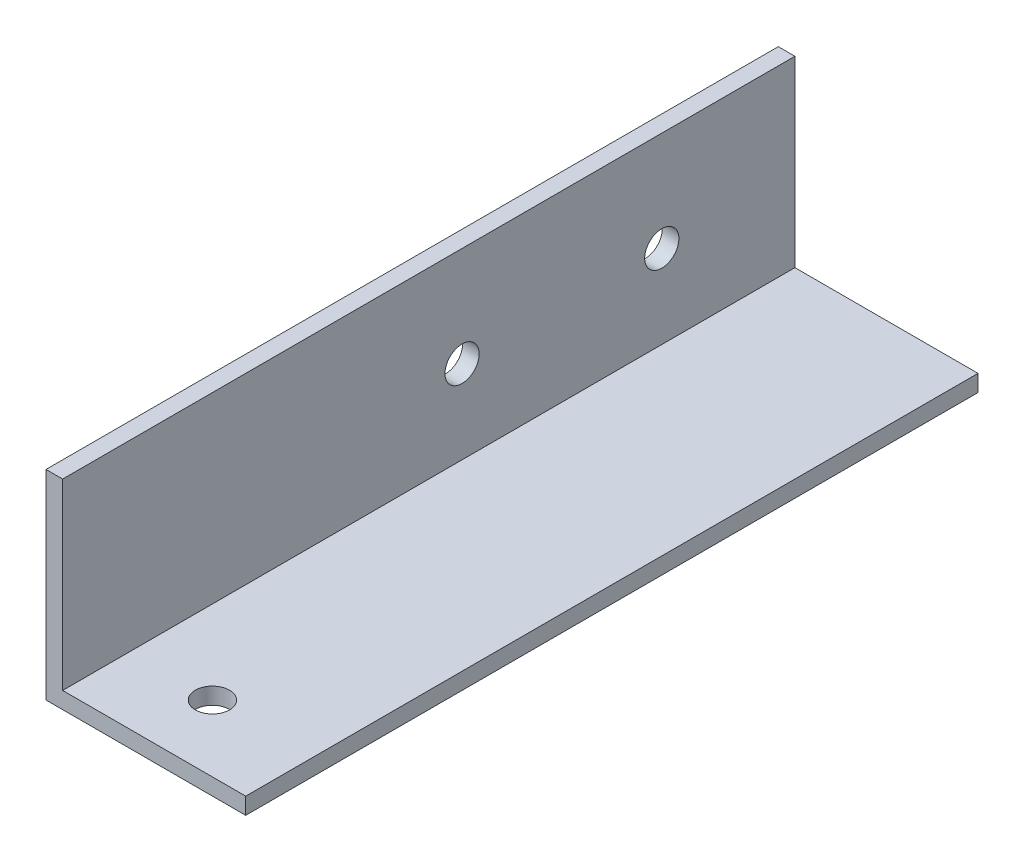
from build123d import *

# Parameters (mm, degrees)
BOSS_EXTRUDE1_DEPTH   = 69.85
F_4_CLEARANCE_HOLE1_D = 3.2639
F_4_CLEARANCE_HOLE2_D = 3.2639


with BuildPart() as part:
    # Sketch1 → Boss-Extrude1 (new body)
    with BuildSketch(Plane.XY):
        Polygon((0, 0), (0, 19.05), (1.5875, 19.05), (1.5875, 1.5875), (19.05, 1.5875), (19.05, 0), align=None)
    extrude(amount=BOSS_EXTRUDE1_DEPTH)

    # #4 Clearance Hole1 (through all)
    with Locations(Plane(origin=(1.5875, 0, 0), x_dir=(0, 0, -1), z_dir=(1, 0, 0))):
        with Locations((-12.7, 9.525), (-31.75, 9.525)):
            Hole(F_4_CLEARANCE_HOLE1_D / 2)

    # #4 Clearance Hole2 (through all)
    with Locations(Plane(origin=(0, 1.5875, 0), x_dir=(1, 0, 0), z_dir=(0, 1, 0))):
        with Locations((9.525, -63.5)):
            Hole(F_4_CLEARANCE_HOLE2_D / 2)


solid = part.part
